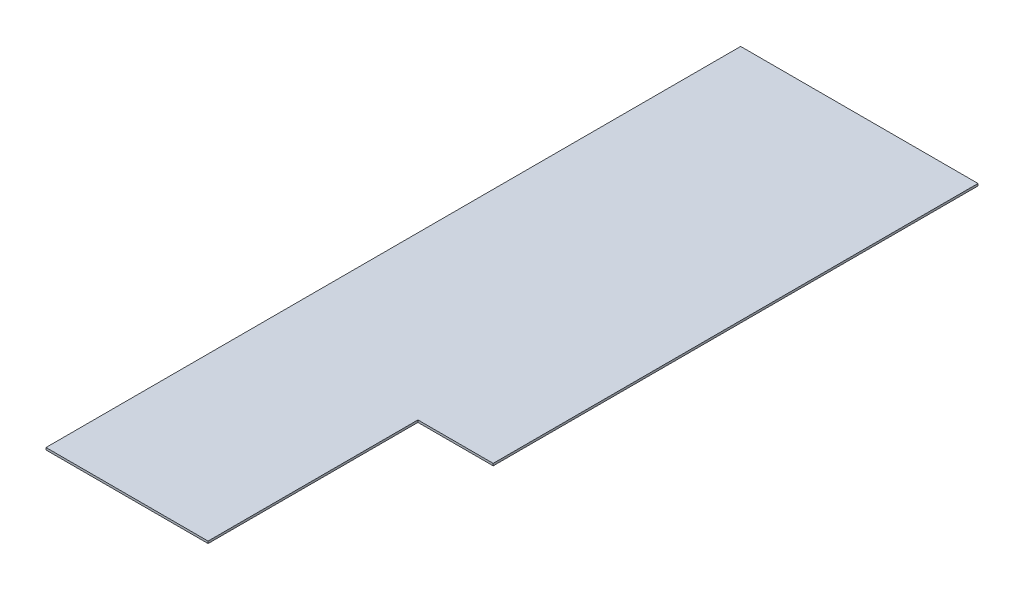
from build123d import *

# Parameters (mm, degrees)
SKETCH1_W           = 520.7
SKETCH1_H           = 1524
BOSS_EXTRUDE1_DEPTH = 4.7752
SKETCH2_W           = 165.1
SKETCH2_H           = 460.375
CUT_EXTRUDE1_DEPTH  = 5.7752


with BuildPart() as part:
    # Sketch1 → Boss-Extrude1 (new body)
    with BuildSketch(Plane(origin=(0, 0, 0), x_dir=(1, 0, 0), z_dir=(0, 1, 0))):
        with Locations((0, 762)):
            Rectangle(SKETCH1_W, SKETCH1_H)
    extrude(amount=BOSS_EXTRUDE1_DEPTH)

    # Sketch2 → Cut-Extrude1 (cut, through all)
    with BuildSketch(Plane(origin=(0, 4.7752, 0), x_dir=(1, 0, 0), z_dir=(0, 1, 0))):
        with Locations((177.8, 230.1875)):
            Rectangle(SKETCH2_W, SKETCH2_H)
    extrude(amount=-CUT_EXTRUDE1_DEPTH, mode=Mode.SUBTRACT)


solid = part.part
